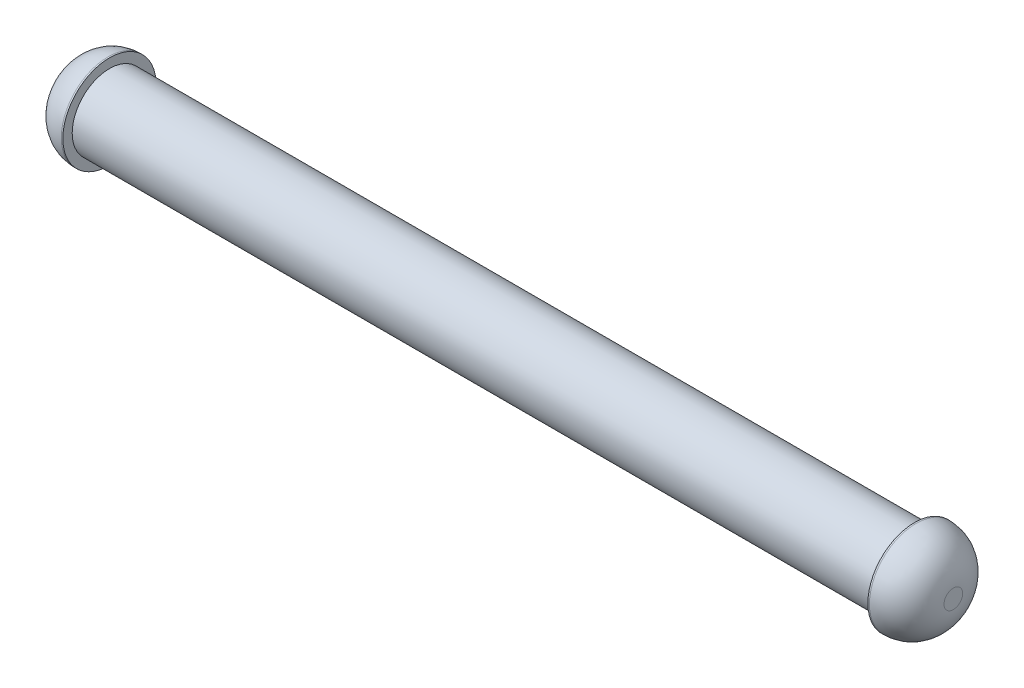
from build123d import *

# Parameters (mm, degrees)
FILLET1_R = 6


with BuildPart() as part:
    # Sketch1 → Revolve1 (revolve)
    with BuildSketch(Plane(origin=(0, 0, 0), x_dir=(1, 0, 0), z_dir=(0, 1, 0))):
        Polygon((-71, 0), (-71, 7.5), (-64.75, 7.5), (-64.75, 6), (64.75, 6), (64.75, 7.5), (71, 7.5), (71, 0), align=None)
    revolve(axis=Axis((-71, 0, 0), (1, 0, 0)))

    # Fillet1
    fillet1_edges = [part.edges().sort_by_distance(p)[0] for p in [
        (-71, 0, 7.5),
        (71, 0, 7.5),
    ]]
    fillet(fillet1_edges, radius=FILLET1_R)


solid = part.part
